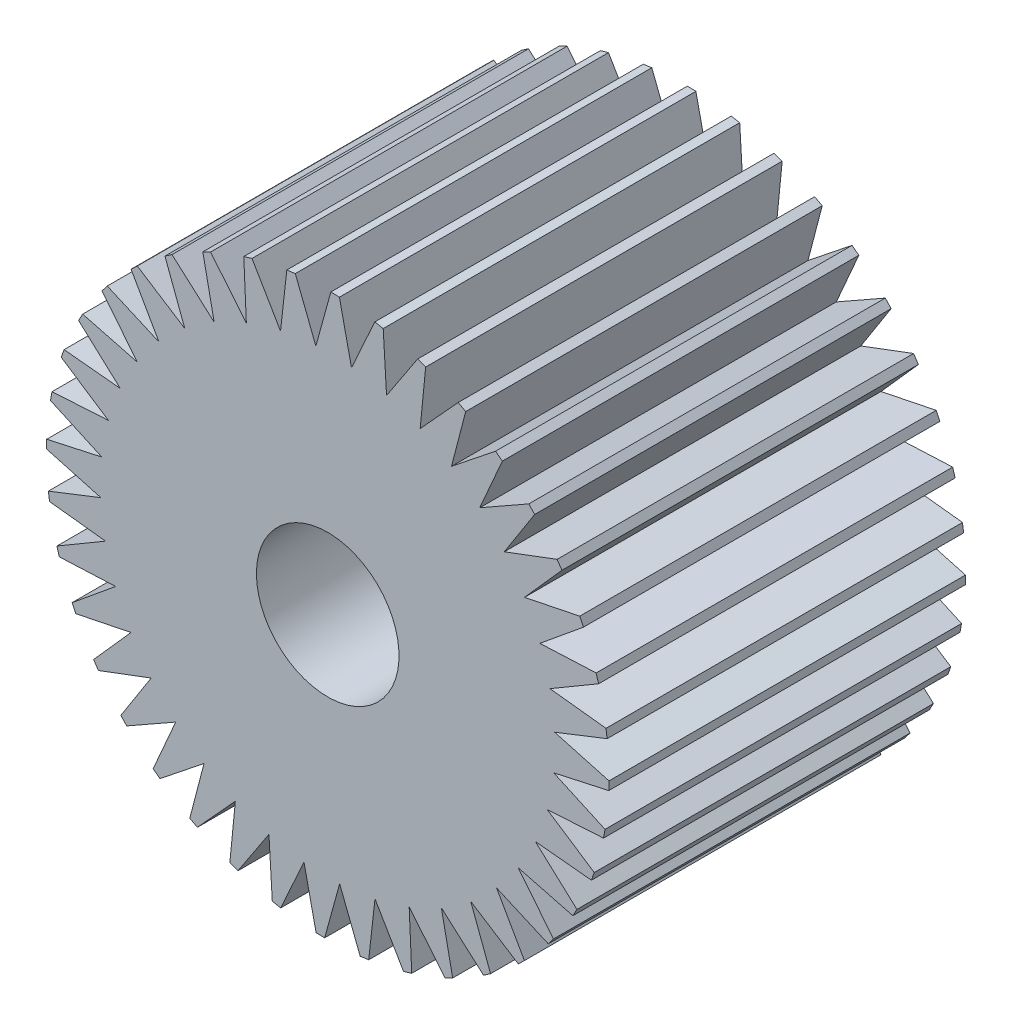
from build123d import *

# Parameters (mm, degrees)
BOSS_EXTRUDE1_DEPTH = 50
SKETCH2_R           = 10
CUT_EXTRUDE1_DEPTH  = 50


with BuildPart() as part:
    # Sketch1 → Boss-Extrude1 (new body)
    with BuildSketch(Plane.XY):
        Polygon((-6.619772583, 31.13494509), (-5.73799784, 38.993038365), (-4.547892767, 39.149686923), (-1.662532106, 31.787453214), (0.437663145, 39.41086036), (1.637621283, 39.379406864), (3.335751275, 31.656444617), (6.602653255, 38.857452051), (7.782917506, 38.638670991), (8.252003232, 30.745145167), (12.605169974, 37.346440186), (13.736678316, 36.945718677), (12.965169329, 29.075994081), (18.297411419, 34.915030894), (19.35230236, 34.342236029), (17.359195772, 26.690091397), (23.539215714, 31.623093539), (24.491514339, 30.892329429), (21.325887048, 23.646185959), (28.201512241, 27.551686544), (29.027769797, 26.680947028), (24.767570054, 20.01922882), (32.169499785, 22.801061463), (32.849371069, 21.811787037), (27.59949913, 15.898527702), (35.345473326, 17.488194451), (35.86221765, 16.404744334), (29.751942786, 11.385547942), (37.651229853, 11.743905927), (37.992123258, 10.592958256), (31.171900714, 6.59141408), (39.029993988, 5.709639337), (39.186642547, 4.519534265), (31.824408837, 1.634173603), (39.447815984, -0.466021647), (39.416362488, -1.665979785), (31.693400241, -3.364109777), (38.894407674, -6.631011757), (38.675626614, -7.811276009), (30.782100791, -8.280361735), (37.38339581, -12.633528476), (36.982674301, -13.765036818), (29.112949705, -12.993527831), (34.951986517, -18.325769921), (34.379191653, -19.380660863), (26.727047021, -17.387554274), (31.660049162, -23.567574216), (30.929285053, -24.519872841), (23.683141582, -21.354245551), (27.588642168, -28.229870743), (26.717902652, -29.056128299), (20.056184443, -24.795928556), (22.838017087, -32.197858288), (21.84874266, -32.877729572), (15.935483325, -27.627857633), (17.525150075, -35.373831828), (16.441699957, -35.890576153), (11.422503566, -29.780301288), (11.78086155, -37.679588355), (10.62991388, -38.02048176), (6.628369704, -31.200259216), (5.746594961, -39.058352491), (4.556489888, -39.215001049), (1.671129227, -31.85276734), (-0.429066024, -39.476174486), (-1.629024161, -39.44472099), (-3.327154153, -31.721758743), (-6.594056134, -38.922766177), (-7.774320385, -38.703985117), (-8.243406111, -30.810459293), (-12.596572853, -37.411754312), (-13.728081194, -37.011032803), (-12.956572207, -29.141308207), (-18.288814298, -34.98034502), (-19.343705239, -34.407550155), (-17.350598651, -26.755405523), (-23.530618592, -31.688407665), (-24.482917218, -30.957643555), (-21.317289927, -23.711500085), (-28.192915119, -27.61700067), (-29.019172675, -26.746261154), (-24.758972932, -20.084542946), (-32.160902664, -22.866375589), (-32.840773948, -21.877101162), (-27.590902009, -15.963841828), (-35.336876204, -17.553508577), (-35.853620529, -16.47005846), (-29.743345665, -11.450862068), (-37.642632731, -11.809220053), (-37.983526136, -10.658272382), (-31.163303592, -6.656728206), (-39.021396867, -5.774953463), (-39.178045425, -4.584848391), (-31.815811716, -1.699487729), (-39.439218862, 0.400707521), (-39.407765367, 1.600665659), (-31.68480312, 3.298795651), (-38.885810553, 6.565697631), (-38.667029493, 7.745961883), (-30.77350367, 8.215047609), (-37.374798689, 12.56821435), (-36.97407718, 13.699722692), (-29.104352583, 12.928213705), (-34.943389396, 18.260455795), (-34.370594532, 19.315346737), (-26.7184499, 17.322240148), (-31.651452041, 23.50226009), (-30.920687932, 24.454558715), (-23.674544461, 21.288931425), (-27.580045047, 28.164556617), (-26.70930553, 28.990814173), (-20.047587322, 24.73061443), (-22.829419966, 32.132544162), (-21.840145539, 32.812415446), (-15.926886204, 27.562543507), (-17.516552954, 35.308517702), (-16.433102836, 35.825262027), (-11.413906444, 29.714987162), (-11.772264429, 37.614274229), (-10.621316758, 37.955167634), align=None)
    extrude(amount=BOSS_EXTRUDE1_DEPTH)

    # Sketch2 → Cut-Extrude1 (cut)
    with BuildSketch(Plane(origin=(0, 0, 0), x_dir=(-1, 0, 0), z_dir=(0, 0, -1))):
        Circle(SKETCH2_R)
    extrude(amount=-CUT_EXTRUDE1_DEPTH, mode=Mode.SUBTRACT)


solid = part.part
